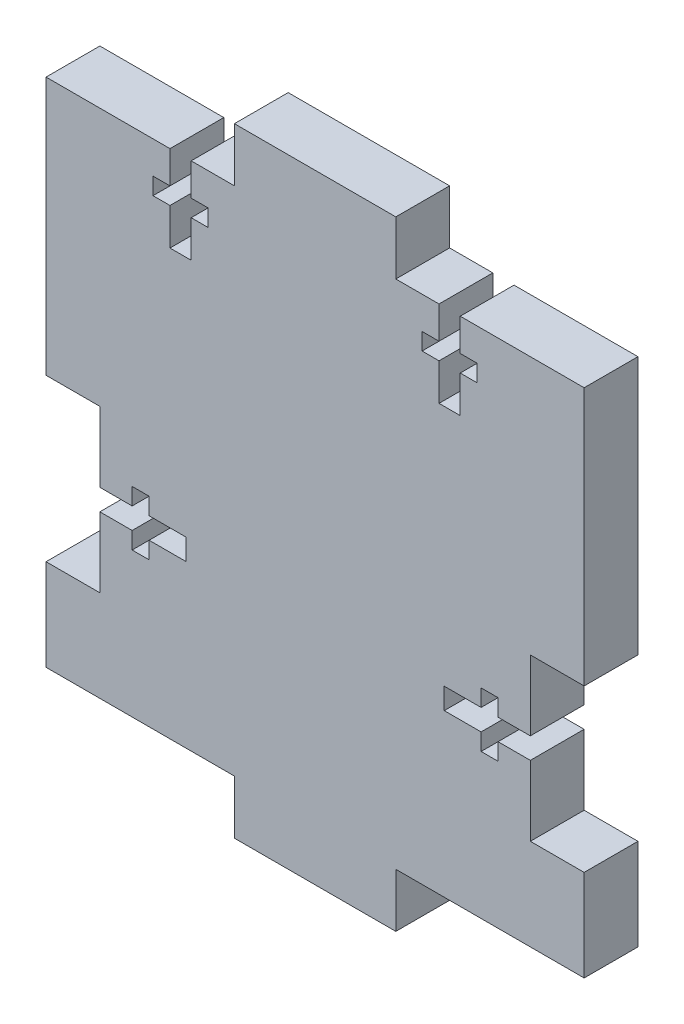
from build123d import *

# Parameters (mm, degrees)
BOSS_EXTRUDE1_DEPTH = 6.35


with BuildPart() as part:
    # Sketch1 → Boss-Extrude1 (new body)
    with BuildSketch(Plane.XY):
        Polygon((0, -6.35), (19.05, -6.35), (19.05, 0), (34.925, 0), (41.275, 0), (41.275, 10.795), (34.925, 10.795), (34.925, 19.07), (31.115, 19.07), (31.115, 17.07), (29.115, 17.07), (29.115, 19.07), (24.765, 19.07), (24.765, 21.57), (29.115, 21.57), (29.115, 23.57), (31.115, 23.57), (31.115, 21.57), (34.925, 21.57), (34.925, 29.845), (41.275, 29.845), (41.275, 60.325), (34.925, 60.325), (26.65, 60.325), (26.65, 56.515), (28.65, 56.515), (28.65, 54.515), (26.65, 54.515), (26.65, 50.165), (24.15, 50.165), (24.15, 54.515), (22.15, 54.515), (22.15, 56.515), (24.15, 56.515), (24.15, 60.325), (19.05, 60.325), (19.05, 66.675), (0, 66.675), (0, 60.325), (-5.1, 60.325), (-5.1, 56.515), (-3.1, 56.515), (-3.1, 54.515), (-5.1, 54.515), (-5.1, 50.165), (-7.6, 50.165), (-7.6, 54.515), (-9.6, 54.515), (-9.6, 56.515), (-7.6, 56.515), (-7.6, 60.325), (-15.875, 60.325), (-22.225, 60.325), (-22.225, 29.845), (-15.875, 29.845), (-15.875, 21.57), (-12.065, 21.57), (-12.065, 23.57), (-10.065, 23.57), (-10.065, 21.57), (-5.715, 21.57), (-5.715, 19.07), (-10.065, 19.07), (-10.065, 17.07), (-12.065, 17.07), (-12.065, 19.07), (-15.875, 19.07), (-15.875, 10.795), (-22.225, 10.795), (-22.225, 0), (-15.875, 0), (0, 0), align=None)
    extrude(amount=BOSS_EXTRUDE1_DEPTH)


solid = part.part
